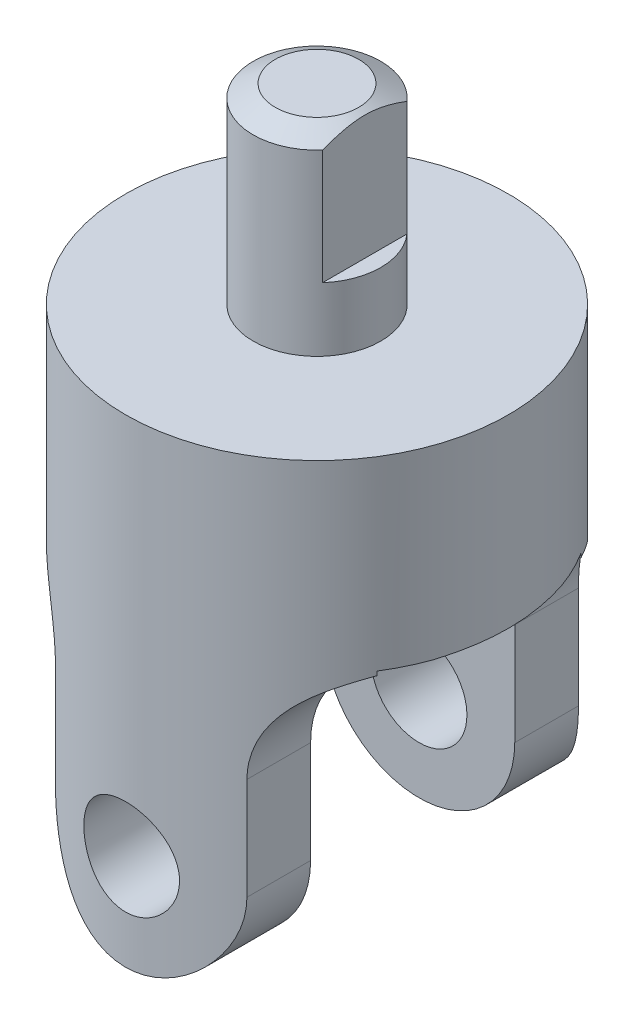
from build123d import *

# Parameters (mm, degrees)
SKETCH1_R               = 19.05
BASE_EXTRUDE_DEPTH      = 47.625
CUT_EXTRUDE1_DEPTH      = 55.716959208
CUT_EXTRUDE1_DEPTH_BACK = 55.716959208
CUT_EXTRUDE5_DEPTH      = 47.625
CUT_EXTRUDE5_DEPTH_BACK = 55.716959365
SKETCH8_W               = 20.32
SKETCH8_H               = 36.600526062
CUT_EXTRUDE6_DEPTH      = 55.716959365
CUT_EXTRUDE6_DEPTH_BACK = 55.716959365
SKETCH11_R              = 4.7625
SKETCH12_R              = 6.35
BOSS_EXTRUDE1_DEPTH     = 19.05
CHAMFER3_SIZE           = 1.27
CHAMFER3_SIZE2          = 2.199704526
CUT_EXTRUDE7_START      = -12.7
CUT_EXTRUDE7_DEPTH      = 12.7


with BuildPart() as part:
    # Sketch1 → Base-Extrude (new body)
    with BuildSketch(Plane(origin=(0, 0, 0), x_dir=(-1, 0, 0), z_dir=(0, 1, 0))):
        Circle(SKETCH1_R)
    extrude(amount=BASE_EXTRUDE_DEPTH)

    # Sketch2 → Cut-Extrude1 (cut, two sides: drawn at the far end of the back side and taken through both)
    with BuildSketch(Plane.XY.offset(-CUT_EXTRUDE1_DEPTH_BACK)):
        with BuildLine():
            Line((9.525, 9.525), (9.525, 19.685))
            ThreePointArc((9.525, 19.685), (12.314807909, 26.420192091), (19.05, 29.21))
            Line((19.05, 29.21), (19.05, -1.366191125))
            Line((19.05, -1.366191125), (-19.05, -1.366191125))
            Line((-19.05, -1.366191125), (-19.05, 29.21))
            ThreePointArc((-19.05, 29.21), (-12.314807909, 26.420192091), (-9.525, 19.685))
            Line((-9.525, 19.685), (-9.525, 9.525))
            ThreePointArc((-9.525, 9.525), (0, 0), (9.525, 9.525))
        make_face()
    extrude(amount=CUT_EXTRUDE1_DEPTH + CUT_EXTRUDE1_DEPTH_BACK, mode=Mode.SUBTRACT)

    # Sketch8 → Cut-Extrude5 (cut, two sides: drawn at the far end of the back side and taken through both)
    with BuildSketch(Plane(origin=(0, 0, 0), x_dir=(0, 0, -1), z_dir=(1, 0, 0)).offset(-CUT_EXTRUDE5_DEPTH_BACK)):
        with Locations((0, 10.844975795)):
            Rectangle(SKETCH8_W, SKETCH8_H)
    extrude(amount=CUT_EXTRUDE5_DEPTH + CUT_EXTRUDE5_DEPTH_BACK, mode=Mode.SUBTRACT)

    # Sketch11 → Cut-Extrude6 (cut, two sides: drawn at the far end of the back side and taken through both)
    with BuildSketch(Plane.XY.offset(-CUT_EXTRUDE6_DEPTH_BACK)):
        with Locations((0, 9.525)):
            Circle(SKETCH11_R)
    extrude(amount=CUT_EXTRUDE6_DEPTH + CUT_EXTRUDE6_DEPTH_BACK, mode=Mode.SUBTRACT)

    # Sketch12 → Boss-Extrude1 (add)
    with BuildSketch(Plane(origin=(0, 47.625, 0), x_dir=(-1, 0, 0), z_dir=(0, 1, 0))):
        Circle(SKETCH12_R)
    extrude(amount=BOSS_EXTRUDE1_DEPTH)

    # Chamfer3
    chamfer3_edges = [part.edges().sort_by_distance(p)[0] for p in [
        (6.35, 66.675, 0),
    ]]
    chamfer3_side = [part.faces().sort_by_distance(p)[0] for p in [
        (6.35, 57.15, 0),
    ]]
    chamfer(chamfer3_edges, length=CHAMFER3_SIZE, length2=CHAMFER3_SIZE2, reference=chamfer3_side[0])

    # Sketch13 → Cut-Extrude7 (cut)
    with BuildSketch(Plane(origin=(0, 66.675, 0), x_dir=(-1, 0, 0), z_dir=(0, 1, 0)).offset(CUT_EXTRUDE7_START)):
        with BuildLine():
            Line((-4.7625, 4.200130206), (-4.7625, -4.200130206))
            ThreePointArc((-4.7625, -4.200130206), (-6.35, 0), (-4.7625, 4.200130206))
        make_face()
    extrude(amount=CUT_EXTRUDE7_DEPTH, mode=Mode.SUBTRACT)


solid = part.part
